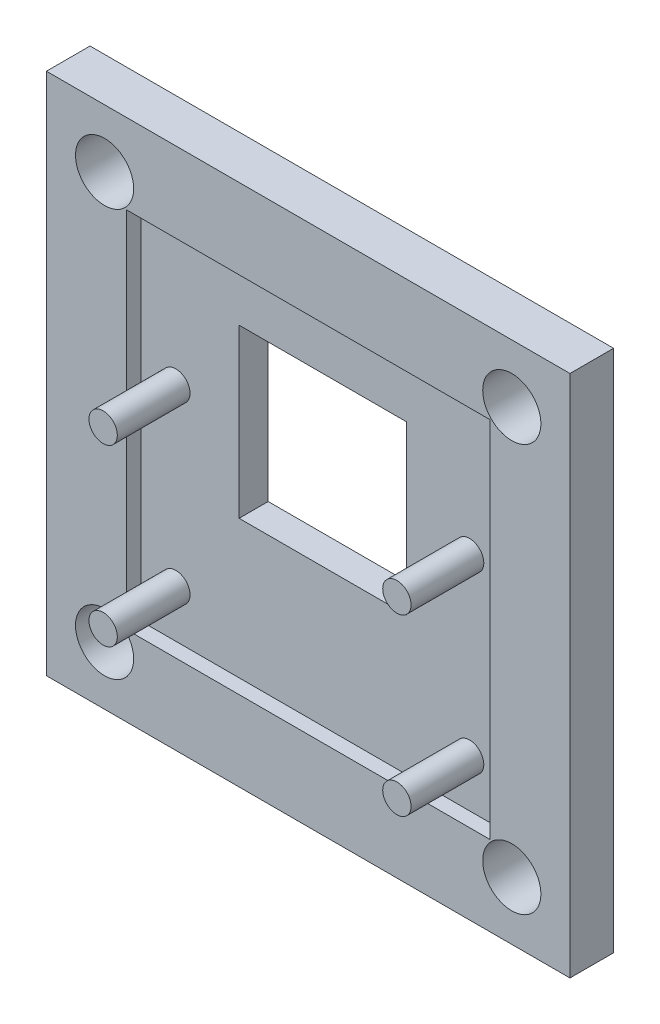
from build123d import *

# Parameters (mm, degrees)
SKETCH1_W           = 36
SKETCH1_H           = 36
BOSS_EXTRUDE1_DEPTH = 3
SKETCH5_R           = 2
CUT_EXTRUDE3_DEPTH  = 10
SKETCH2_W           = 25
SKETCH2_H           = 25
CUT_EXTRUDE1_DEPTH  = 1
SKETCH4_W           = 11.5
SKETCH4_H           = 11.5
CUT_EXTRUDE4_DEPTH  = 3
SKETCH3_R           = 0.975
BOSS_EXTRUDE2_DEPTH = 5


with BuildPart() as part:
    # Sketch1 → Boss-Extrude1 (new body)
    with BuildSketch(Plane.XY):
        Rectangle(SKETCH1_W, SKETCH1_H)
    extrude(amount=BOSS_EXTRUDE1_DEPTH)

    # Sketch5 → Cut-Extrude3 (cut)
    with BuildSketch(Plane.XY.offset(3)):
        with Locations((-14, 14)):
            Circle(SKETCH5_R)
        with Locations((-14, -14)):
            Circle(SKETCH5_R)
        with Locations((14, -14)):
            Circle(SKETCH5_R)
        with Locations((14, 14)):
            Circle(SKETCH5_R)
    extrude(amount=-CUT_EXTRUDE3_DEPTH, mode=Mode.SUBTRACT)

    # Sketch2 → Cut-Extrude1 (cut)
    with BuildSketch(Plane.XY.offset(3)):
        Rectangle(SKETCH2_W, SKETCH2_H)
    extrude(amount=-CUT_EXTRUDE1_DEPTH, mode=Mode.SUBTRACT)

    # Sketch4 → Cut-Extrude4 (cut, through all)
    with BuildSketch(Plane.XY.offset(2)):
        with Locations((0, 2.75)):
            Rectangle(SKETCH4_W, SKETCH4_H)
    extrude(amount=-CUT_EXTRUDE4_DEPTH, mode=Mode.SUBTRACT)

    # Sketch3 → Boss-Extrude2 (add)
    with BuildSketch(Plane.XY.offset(2)):
        with Locations((10.1, 2.75)):
            Circle(SKETCH3_R)
        with Locations((10.1, -9.25)):
            Circle(SKETCH3_R)
        with Locations((-10.1, -9.25)):
            Circle(SKETCH3_R)
        with Locations((-10.1, 2.75)):
            Circle(SKETCH3_R)
    extrude(amount=BOSS_EXTRUDE2_DEPTH)


solid = part.part
